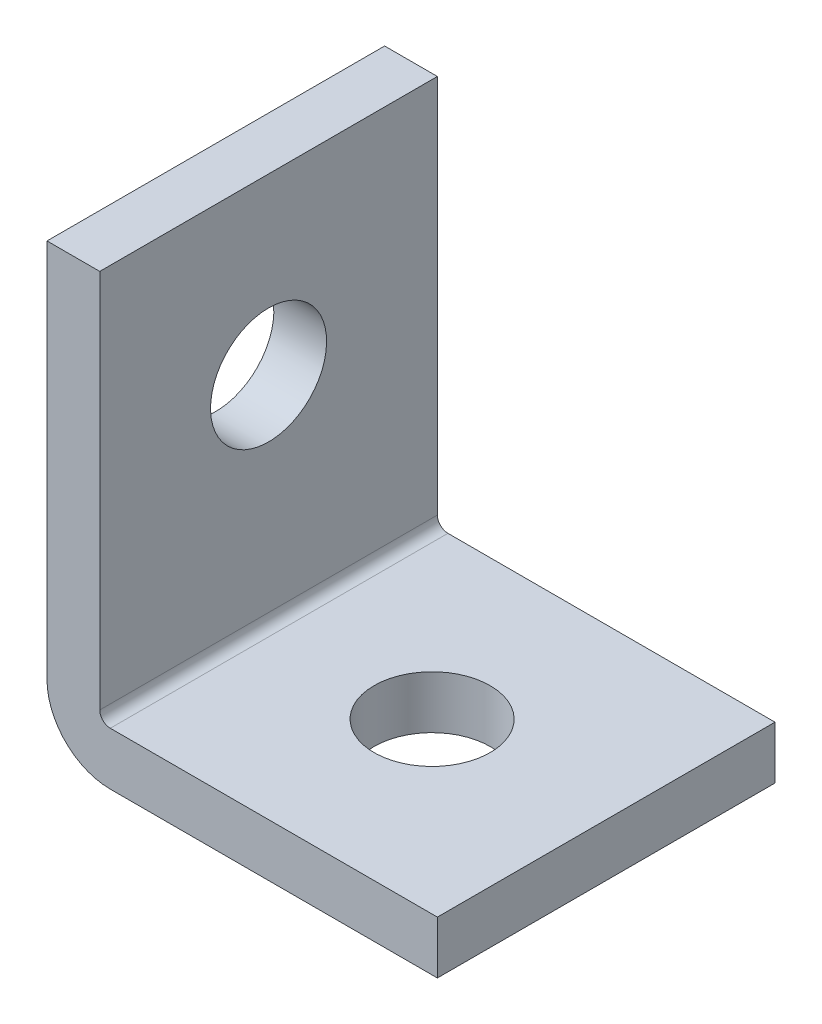
from build123d import *

# Parameters (mm, degrees)
BOSS_EXTRUDE1_DEPTH = 20.32
CUT_EXTRUDE1_REACH  = 8.35
SKETCH2_R           = 6.985
CUT_EXTRUDE2_REACH  = 8.35
SKETCH3_R           = 6.985


with BuildPart() as part:
    # Sketch1 → Boss-Extrude1 (new body, symmetric)
    with BuildSketch(Plane.XY):
        with BuildLine():
            Line((0, 1.27), (0, 46.99))
            Line((0, 46.99), (-6.35, 46.99))
            Line((-6.35, 46.99), (-6.35, 1.27))
            ThreePointArc((-6.35, 1.27), (-4.118153673, -4.118153673), (1.27, -6.35))
            Line((1.27, -6.35), (40.64, -6.35))
            Line((40.64, -6.35), (40.64, 0))
            Line((40.64, 0), (1.27, 0))
            ThreePointArc((1.27, 0), (0.371974388, 0.371974388), (0, 1.27))
        make_face()
    extrude(amount=BOSS_EXTRUDE1_DEPTH, both=True)

    # Sketch2 → Cut-Extrude1 (cut, up to next)
    with BuildSketch(Plane(origin=(0, 0, 0), x_dir=(0, 0, -1), z_dir=(1, 0, 0)), mode=Mode.PRIVATE) as cut_extrude1_sk1:
        with Locations((0, 26.035)):
            Circle(SKETCH2_R)
    cut_extrude1_tool1 = extrude(cut_extrude1_sk1.sketch, amount=-CUT_EXTRUDE1_REACH, mode=Mode.PRIVATE) & part.part
    add(cut_extrude1_tool1.solids().sort_by_distance((0, 26.035, 0))[0], mode=Mode.SUBTRACT)

    # Sketch3 → Cut-Extrude2 (cut, up to next)
    with BuildSketch(Plane(origin=(0, 0, 0), x_dir=(1, 0, 0), z_dir=(0, 1, 0)), mode=Mode.PRIVATE) as cut_extrude2_sk1:
        with Locations((19.685, 0)):
            Circle(SKETCH3_R)
    cut_extrude2_tool1 = extrude(cut_extrude2_sk1.sketch, amount=-CUT_EXTRUDE2_REACH, mode=Mode.PRIVATE) & part.part
    add(cut_extrude2_tool1.solids().sort_by_distance((19.685, 0, 0))[0], mode=Mode.SUBTRACT)


solid = part.part
